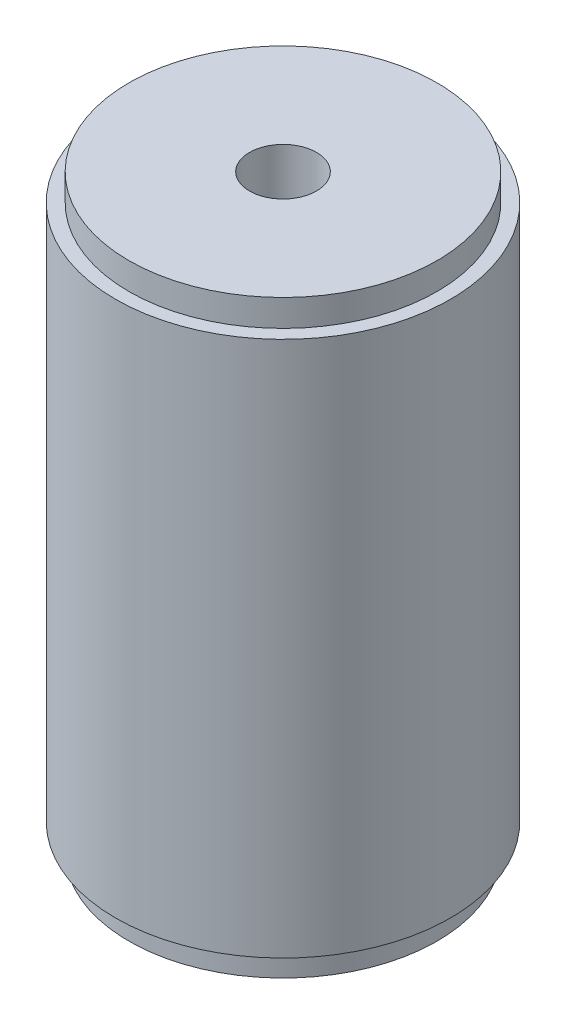
from build123d import *

# Parameters (mm, degrees)
SKETCH1_R               = 12.5
BOSS_EXTRUDE1_DEPTH     = 40
SKETCH2_R               = 11.5
BOSS_EXTRUDE2_DEPTH     = 2
SKETCH3_R               = 11.5
BOSS_EXTRUDE3_DEPTH     = 2
SKETCH4_R               = 2.5
CUT_EXTRUDE1_DEPTH      = 1
CUT_EXTRUDE1_DEPTH_BACK = 45


with BuildPart() as part:
    # Sketch1 → Boss-Extrude1 (new body)
    with BuildSketch(Plane(origin=(0, 0, 0), x_dir=(1, 0, 0), z_dir=(0, 1, 0))):
        Circle(SKETCH1_R)
    extrude(amount=BOSS_EXTRUDE1_DEPTH)

    # Sketch2 → Boss-Extrude2 (add)
    with BuildSketch(Plane(origin=(0, 40, 0), x_dir=(1, 0, 0), z_dir=(0, 1, 0))):
        Circle(SKETCH2_R)
    extrude(amount=BOSS_EXTRUDE2_DEPTH)

    # Sketch3 → Boss-Extrude3 (add)
    with BuildSketch(Plane.XZ):
        Circle(SKETCH3_R)
    extrude(amount=BOSS_EXTRUDE3_DEPTH)

    # Sketch4 → Cut-Extrude1 (cut, two sides)
    with BuildSketch(Plane(origin=(0, -2, 0), x_dir=(-1, 0, 0), z_dir=(0, -1, 0))) as cut_extrude1_sk:
        Circle(SKETCH4_R)
    extrude(amount=CUT_EXTRUDE1_DEPTH, mode=Mode.SUBTRACT)
    extrude(cut_extrude1_sk.sketch, amount=-CUT_EXTRUDE1_DEPTH_BACK, mode=Mode.SUBTRACT)


solid = part.part
